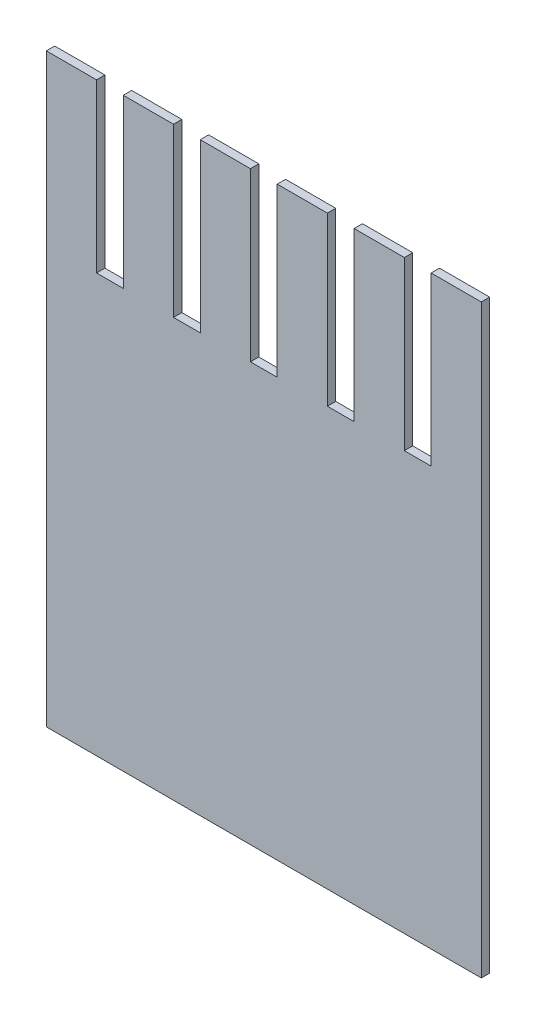
from build123d import *

# Parameters (mm, degrees)
BOSS_EXTRUDE1_DEPTH = 0.5


with BuildPart() as part:
    # Sketch1 → Boss-Extrude1 (new body)
    with BuildSketch(Plane.XY):
        Polygon((0, 35), (0, 0), (26, 0), (26, 35), (23, 35), (23, 25), (21.4, 25), (21.4, 35), (18.4, 35), (18.4, 25), (16.8, 25), (16.8, 35), (13.8, 35), (13.8, 25), (12.2, 25), (12.2, 35), (9.2, 35), (9.2, 25), (7.6, 25), (7.6, 35), (4.6, 35), (4.6, 25), (3, 25), (3, 35), align=None)
    extrude(amount=BOSS_EXTRUDE1_DEPTH)


solid = part.part
